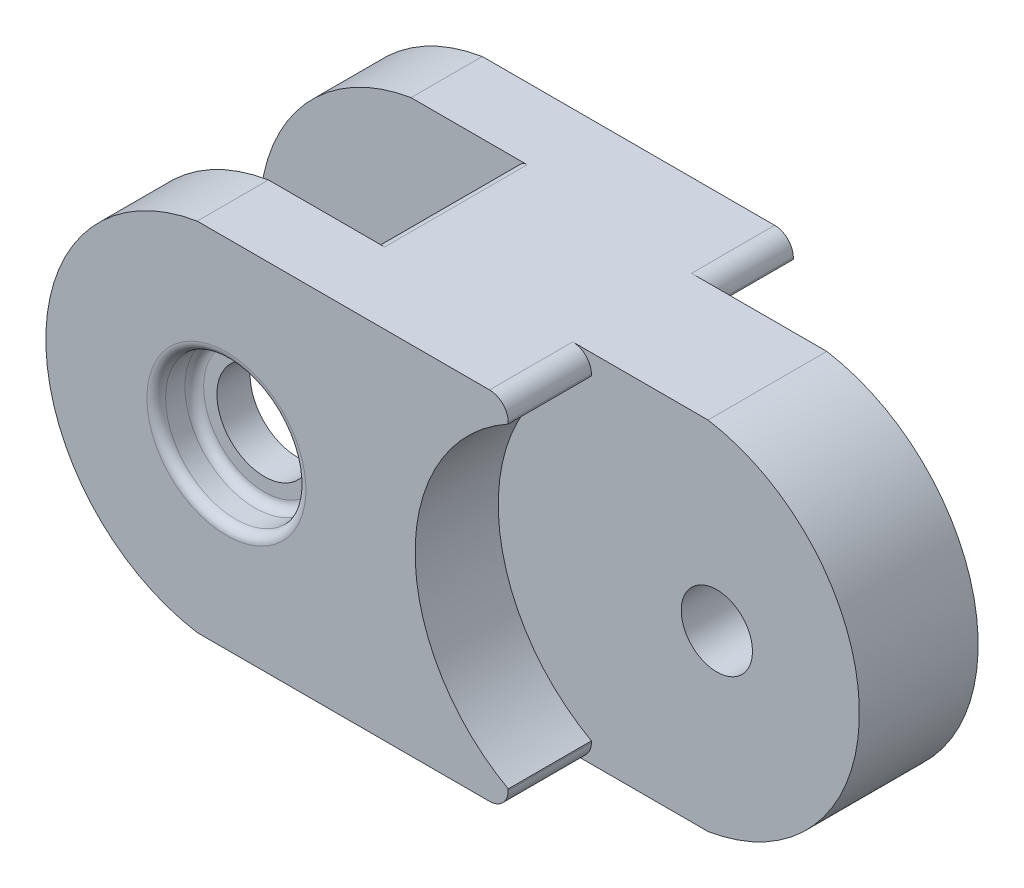
from build123d import *

# Parameters (mm, degrees)
SKETCH1_W                                       = 22.86
SKETCH1_H                                       = 15.24
BOSS_EXTRUDE1_DEPTH                             = 19.05
BOSS_EXTRUDE3_DEPTH                             = 3.81
LPATTERN1_COUNT                                 = 2
LPATTERN1_PITCH                                 = 11.43
SKETCH5_R                                       = 1.905
CUT_EXTRUDE2_DEPTH                              = 16.24
CUT_EXTRUDE3_DEPTH                              = 3.81
BOSS_EXTRUDE6_DEPTH                             = 3.175
SKETCH9_R                                       = 1.905
CUT_EXTRUDE4_DEPTH                              = 6.35
CUT_EXTRUDE5_DEPTH                              = 4.445
LPATTERN2_COUNT                                 = 2
LPATTERN2_PITCH                                 = 10.795
CBORE_FOR_6_PAN_HEAD_MACHINE_SCREW3_D           = 3.7500052
CBORE_FOR_6_PAN_HEAD_MACHINE_SCREW3_CBORE_D     = 7.5000104
CBORE_FOR_6_PAN_HEAD_MACHINE_SCREW3_CBORE_DEPTH = 2.032
SKETCH18_R                                      = 2.54
CUT_EXTRUDE8_DEPTH                              = 1.778
FILLET2_R                                       = 0.5
FILLET3_R                                       = 0.5
SKETCH19_W                                      = 3.111810153
SKETCH19_H                                      = 4.445
CUT_EXTRUDE9_DEPTH                              = 19.05
LPATTERN3_COUNT                                 = 2
LPATTERN3_PITCH                                 = 10.795
FILLET4_R                                       = 1


with BuildPart() as part:
    # Sketch1 → Boss-Extrude1 (new body)
    with BuildSketch(Plane(origin=(0, 0, 0), x_dir=(1, 0, 0), z_dir=(0, 1, 0))):
        Rectangle(SKETCH1_W, SKETCH1_H)
    extrude(amount=BOSS_EXTRUDE1_DEPTH)

    # Sketch3 → Boss-Extrude3 (add)
    with BuildSketch(Plane.XY.offset(7.62)):
        with BuildLine():
            Line((-11.43, 19.05), (-11.43, 0))
            ThreePointArc((-11.43, 0), (-19.521397873, 9.525), (-11.43, 19.05))
        make_face()
    boss_extrude3 = extrude(amount=-BOSS_EXTRUDE3_DEPTH)

    # LPattern1: Boss-Extrude3 ×2
    with Locations(*[(0, 0, -i * LPATTERN1_PITCH) for i in range(1, LPATTERN1_COUNT)]):
        add(boss_extrude3)

    # Sketch5 → Cut-Extrude2 (cut, through all)
    with BuildSketch(Plane.XY.offset(7.62)):
        with Locations((-9.869397873, 9.525)):
            Circle(SKETCH5_R)
    extrude(amount=-CUT_EXTRUDE2_DEPTH, mode=Mode.SUBTRACT)

    # Sketch6 → Cut-Extrude3 (cut, symmetric)
    with BuildSketch(Plane.XY):
        with BuildLine():
            Line((-11.43, 19.05), (-11.43, 0))
            ThreePointArc((-11.43, 0), (-0.217397873, 9.525), (-11.43, 19.05))
        make_face()
    extrude(amount=CUT_EXTRUDE3_DEPTH, both=True, mode=Mode.SUBTRACT)

    # Sketch8 → Boss-Extrude6 (add, symmetric)
    with BuildSketch(Plane.XY):
        with BuildLine():
            Line((11.43, 19.05), (11.43, 0))
            ThreePointArc((11.43, 0), (19.521397873, 9.525), (11.43, 19.05))
        make_face()
    extrude(amount=BOSS_EXTRUDE6_DEPTH, both=True)

    # Sketch9 → Cut-Extrude4 (cut)
    with BuildSketch(Plane.XY.offset(3.175)):
        with Locations(Location((11.901397873, 9.525, 0), (0, 0, 104.32684201))):  # turned: the seam where the file's is
            Circle(SKETCH9_R)
    extrude(amount=-CUT_EXTRUDE4_DEPTH, mode=Mode.SUBTRACT)

    # Sketch10 → Cut-Extrude5 (cut)
    with BuildSketch(Plane.XY.offset(3.175)):
        with BuildLine():
            Line((11.43, 19.05), (11.43, 0))
            ThreePointArc((11.43, 0), (0.217397873, 9.525), (11.43, 19.05))
        make_face()
    cut_extrude5 = extrude(amount=CUT_EXTRUDE5_DEPTH, mode=Mode.SUBTRACT)

    # LPattern2: Cut-Extrude5 ×2
    with Locations(*[(0, 0, -i * LPATTERN2_PITCH) for i in range(1, LPATTERN2_COUNT)]):
        add(cut_extrude5, mode=Mode.SUBTRACT)

    # CBORE for #6 Pan Head Machine Screw3 (through all)
    with Locations(Plane.XY.offset(7.62)):
        with Locations((-9.869397873, 9.525)):
            CounterBoreHole(CBORE_FOR_6_PAN_HEAD_MACHINE_SCREW3_D / 2, CBORE_FOR_6_PAN_HEAD_MACHINE_SCREW3_CBORE_D / 2, CBORE_FOR_6_PAN_HEAD_MACHINE_SCREW3_CBORE_DEPTH)

    # Sketch18 → Cut-Extrude8 (cut)
    with BuildSketch(Plane.XY.offset(5.588)):
        with Locations((-9.869397873, 9.525)):
            Circle(SKETCH18_R)
    extrude(amount=-CUT_EXTRUDE8_DEPTH, mode=Mode.SUBTRACT)

    # Fillet2
    fillet2_edges = [part.edges().sort_by_distance(p)[0] for p in [
        (-8.308795745, 19.05, 0),
        (-8.308795745, 0, 0),
    ]]
    fillet(fillet2_edges, radius=FILLET2_R)

    # Fillet3
    fillet3_edges = [part.edges().sort_by_distance(p)[0] for p in [
        (-13.619403073, 9.525, 7.62),
        (-13.619403073, 9.525, 5.588),
    ]]
    fillet(fillet3_edges, radius=FILLET3_R)

    # Sketch19 → Cut-Extrude9 (cut)
    with BuildSketch(Plane(origin=(0, 19.05, 0), x_dir=(1, 0, 0), z_dir=(0, 1, 0))):
        with Locations((6.752890669, -5.3975)):
            Rectangle(SKETCH19_W, SKETCH19_H)
    cut_extrude9 = extrude(amount=-CUT_EXTRUDE9_DEPTH, mode=Mode.SUBTRACT)

    # LPattern3: Cut-Extrude9 ×2
    with Locations(*[(0, 0, -i * LPATTERN3_PITCH) for i in range(1, LPATTERN3_COUNT)]):
        add(cut_extrude9, mode=Mode.SUBTRACT)

    # Fillet4
    fillet4_edges = [part.edges().sort_by_distance(p)[0] for p in [
        (5.196985592, 19.05, 5.3975),
        (5.196985592, 0, 5.3975),
        (5.196985592, 19.05, -5.3975),
        (5.196985592, 0, -5.3975),
    ]]
    fillet(fillet4_edges, radius=FILLET4_R)


solid = part.part
